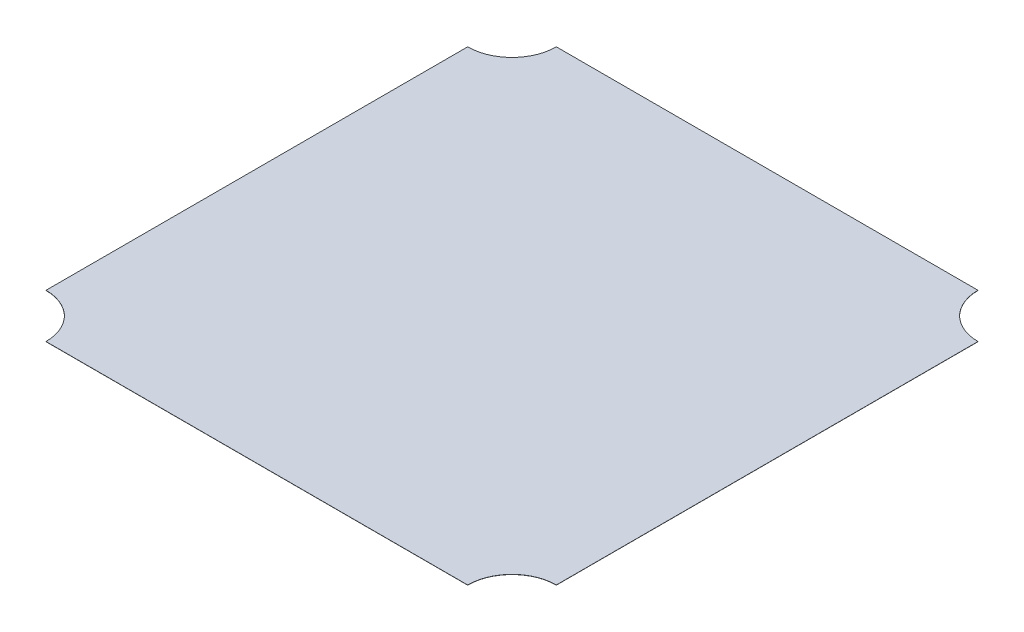
from build123d import *

# Parameters (mm, degrees)
SKETCH3_W                = 152.4
SKETCH3_H                = 0.0508
BOSS_EXTRUDE1_DEPTH      = 76.2
BOSS_EXTRUDE1_DEPTH_BACK = 76.2
CUT_EXTRUDE4_DEPTH       = 25.4


with BuildPart() as part:
    # Sketch3 → Boss-Extrude1 (new, two sides)
    with BuildSketch(Plane.XY) as boss_extrude1_sk:
        Rectangle(SKETCH3_W, SKETCH3_H)
    extrude(amount=BOSS_EXTRUDE1_DEPTH)
    extrude(boss_extrude1_sk.sketch, amount=-BOSS_EXTRUDE1_DEPTH_BACK)

    # Sketch7 → Cut-Extrude4 (cut, symmetric)
    with BuildSketch(Plane(origin=(0, 0.0254, 0), x_dir=(1, 0, 0), z_dir=(0, 1, 0))):
        with BuildLine():
            Line((-63.5, 76.2), (-76.2, 76.2))
            Line((-76.2, 76.2), (-76.2, 63.5))
            ThreePointArc((-76.2, 63.5), (-67.219743879, 67.219743879), (-63.5, 76.2))
        make_face()
        with BuildLine():
            Line((-76.2, -57.15), (-76.2, -76.2))
            Line((-76.2, -76.2), (76.2, -76.2))
            Line((76.2, -76.2), (76.2, 76.2))
            Line((76.2, 76.2), (57.15, 76.2))
            ThreePointArc((57.15, 76.2), (60.869743879, 67.219743879), (69.85, 63.5))
            Line((69.85, 63.5), (69.85, -57.15))
            ThreePointArc((69.85, -57.15), (60.869743879, -60.869743879), (57.15, -69.85))
            Line((57.15, -69.85), (-63.5, -69.85))
            ThreePointArc((-63.5, -69.85), (-67.219743879, -60.869743879), (-76.2, -57.15))
        make_face()
    extrude(amount=CUT_EXTRUDE4_DEPTH, both=True, mode=Mode.SUBTRACT)


solid = part.part
